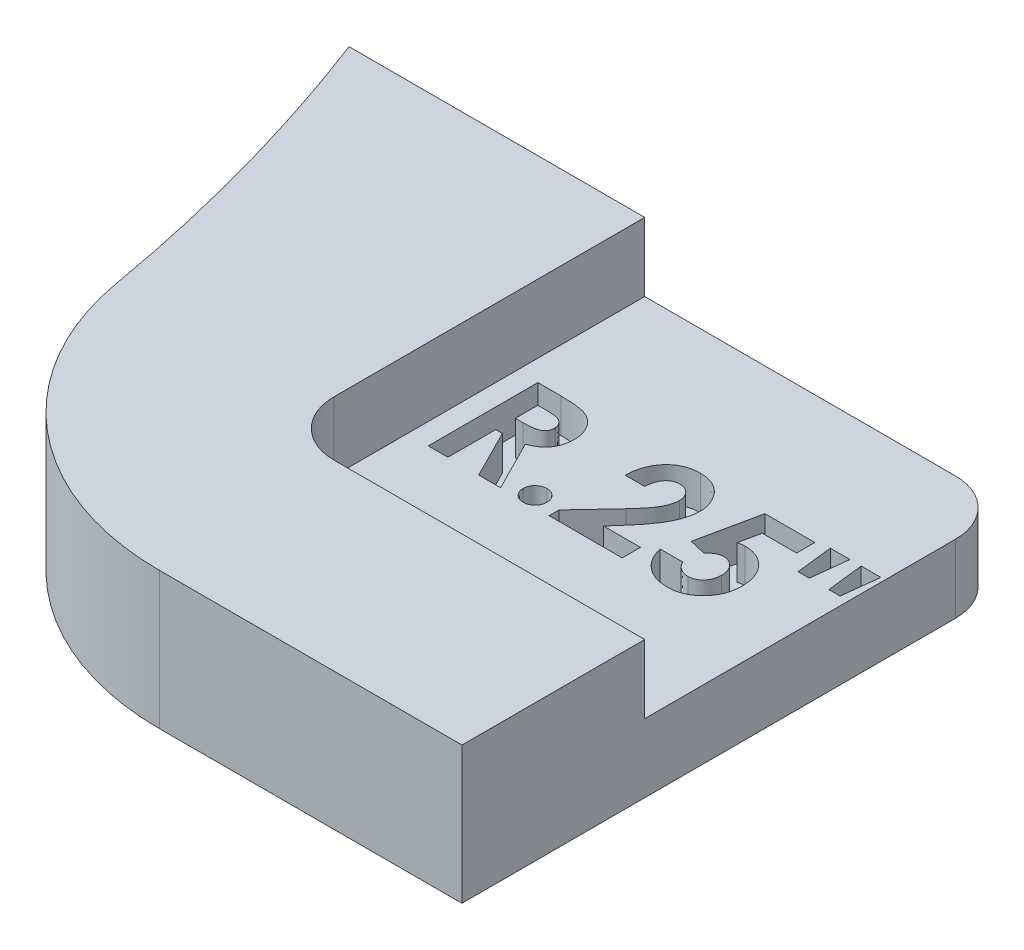
from build123d import *

# Parameters (mm, degrees)
BOSS_EXTRUDE1_DEPTH = 1.5875
FILLET1_R           = 6.35
SKETCH3_W           = 8.466666667
SKETCH3_H           = 8.466666667
CUT_EXTRUDE1_DEPTH  = 1.5875
CUT_EXTRUDE2_DEPTH  = 0.79375
FILLET2_R           = 1.27


with BuildPart() as part:
    # Sketch2 → Boss-Extrude1 (new, symmetric)
    with BuildSketch(Plane(origin=(0, 0, 0), x_dir=(1, 0, 0), z_dir=(0, 1, 0))):
        with BuildLine():
            Line((39.871809281, 1.5875), (52.571809281, 1.5875))
            Line((52.571809281, 1.5875), (52.571809281, 14.2875))
            Line((52.571809281, 14.2875), (37.257867294, 14.2875))
            ThreePointArc((37.257867294, 14.2875), (39.084130438, 8.044381855), (39.871809281, 1.5875))
        make_face()
    extrude(amount=BOSS_EXTRUDE1_DEPTH, both=True)

    # Fillet1
    fillet1_edges = [part.edges().sort_by_distance(p)[0] for p in [
        (39.871809281, 0, -1.5875),
    ]]
    fillet(fillet1_edges, radius=FILLET1_R)

    # Sketch3 → Cut-Extrude1 (cut)
    with BuildSketch(Plane(origin=(0, 1.5875, 0), x_dir=(1, 0, 0), z_dir=(0, 1, 0))):
        with Locations((48.338475948, 10.054166667)):
            Rectangle(SKETCH3_W, SKETCH3_H)
    extrude(amount=-CUT_EXTRUDE1_DEPTH, mode=Mode.SUBTRACT)

    # Sketch4 → Cut-Extrude2 (cut)
    with BuildSketch(Plane(origin=(0, 0, 0), x_dir=(1, 0, 0), z_dir=(0, 1, 0))):
        with BuildLine():
            Line((44.593604152, 11.324166667), (45.124806075, 11.324166667))
            add(Edge.make_bspline(
                [(45.124806075, 11.324166667), (45.159918361, 11.324042038), (45.227449176, 11.323802343), (45.324824924, 11.32002058), (45.414277939, 11.314757948), (45.495940666, 11.306727031), (45.569778167, 11.296079006), (45.635864445, 11.283526746), (45.694197569, 11.269220755), (45.745269497, 11.251394362), (45.791359386, 11.23128646), (45.834321571, 11.208182112), (45.875103861, 11.182338593), (45.91343367, 11.153075889), (45.949644094, 11.120920429), (45.983803445, 11.085839845), (46.01542902, 11.047536669), (46.044324993, 11.006252927), (46.070661346, 10.962823378), (46.093937159, 10.917188393), (46.112865088, 10.869316234), (46.129589943, 10.819898758), (46.141636314, 10.768229533), (46.150014389, 10.714811567), (46.156148488, 10.659456824), (46.156501169, 10.621851269), (46.156681075, 10.602668269)],
                knots=[0, 0, 0, 0, 1.749336639, 3.364467119, 4.854658419, 6.213483162, 7.451590619, 8.570285859, 9.5643256, 10.440900261, 11.26203566, 12.067320669, 12.869050712, 13.665104639, 14.467235401, 15.27997916, 16.102287765, 16.939272006, 17.78853747, 18.631303466, 19.488103222, 20.351255419, 21.228522269, 22.127379805, 23.044756219, 24, 24, 24, 24], degree=3))
            add(Edge.make_bspline(
                [(46.156681075, 10.602668269), (46.156213743, 10.582645624), (46.155297389, 10.543384867), (46.150361408, 10.485714017), (46.141339985, 10.430538582), (46.127675728, 10.378020108), (46.11197044, 10.327504941), (46.091086435, 10.27992512), (46.067516771, 10.234588662), (46.03952377, 10.192136871), (46.008802818, 10.151626807), (45.973074998, 10.114610561), (45.934654923, 10.079098649), (45.891382861, 10.047315418), (45.845166284, 10.0171118), (45.795086918, 9.989739279), (45.741471598, 9.964509772), (45.703777373, 9.950440056), (45.684501588, 9.943245192)],
                knots=[0, 0, 0, 0, 1.099860209, 2.156625411, 3.176576793, 4.16617041, 5.135385252, 6.078461593, 7.016046972, 7.938469504, 8.868247731, 9.803980173, 10.76021508, 11.73834243, 12.748633912, 13.790971185, 14.870363756, 16, 16, 16, 16], degree=3))
            Line((45.684501588, 9.943245192), (46.270655434, 8.784166667))
            Line((46.270655434, 8.784166667), (45.763876588, 8.784166667))
            Line((45.763876588, 8.784166667), (45.204181075, 9.891346154))
            Line((45.204181075, 9.891346154), (45.049501588, 9.891346154))
            Line((45.049501588, 9.891346154), (45.049501588, 8.784166667))
            Line((45.049501588, 8.784166667), (44.593604152, 8.784166667))
            Line((44.593604152, 8.784166667), (44.593604152, 11.324166667))
        make_face()
        with BuildLine():
            Line((45.049501588, 10.34724359), (45.22707771, 10.34724359))
            add(Edge.make_bspline(
                [(45.22707771, 10.34724359), (45.248787867, 10.347488104), (45.290358153, 10.347956297), (45.350141684, 10.350127967), (45.404439387, 10.355360621), (45.453484436, 10.361971884), (45.497523621, 10.369605541), (45.536164127, 10.380545035), (45.570001346, 10.39226698), (45.598634306, 10.406834317), (45.623097649, 10.423400538), (45.64422018, 10.442220178), (45.661691542, 10.464001514), (45.676071363, 10.488152625), (45.687257301, 10.51488712), (45.695422179, 10.543911516), (45.699985138, 10.575556438), (45.700510122, 10.597395742), (45.70078364, 10.608774038)],
                knots=[0, 0, 0, 0, 1.688639943, 3.233382647, 4.650958383, 5.928841754, 7.082724185, 8.122798841, 9.049171256, 9.863274652, 10.613301712, 11.341792392, 12.054588806, 12.776240173, 13.521029143, 14.301969904, 15.115324896, 16, 16, 16, 16], degree=3))
            add(Edge.make_bspline(
                [(45.70078364, 10.608774038), (45.70026653, 10.622235393), (45.699250765, 10.648677731), (45.68917122, 10.686745424), (45.673126761, 10.72197968), (45.651134202, 10.754221299), (45.623437433, 10.782486528), (45.591653205, 10.807402553), (45.555095539, 10.827104281), (45.521245891, 10.840099331), (45.490450623, 10.847874404), (45.462658866, 10.853668319), (45.430475843, 10.857774633), (45.393877259, 10.86213011), (45.352956405, 10.864954416), (45.307490237, 10.867015597), (45.257609334, 10.867858927), (45.222837607, 10.868128525), (45.20468989, 10.868269231)],
                knots=[0, 0, 0, 0, 1.020303359, 2.004196876, 2.966617323, 3.9489082, 4.950758222, 5.960522915, 7.003732012, 8.091992268, 8.70421221, 9.413913587, 10.24622431, 11.166358409, 12.212345909, 13.359657661, 14.621978493, 16, 16, 16, 16], degree=3))
            Line((45.20468989, 10.868269231), (45.049501588, 10.868269231))
            Line((45.049501588, 10.868269231), (45.049501588, 10.34724359))
        make_face(mode=Mode.SUBTRACT)
        with BuildLine():
            add(Edge.make_bspline(
                [(46.824245178, 9.305192308), (46.842649217, 9.304183258), (46.878883591, 9.302196615), (46.931237321, 9.287370501), (46.978486864, 9.260733275), (47.020734269, 9.22598963), (47.05645761, 9.184188387), (47.082277634, 9.13651918), (47.09835641, 9.084367176), (47.100131518, 9.048018804), (47.10104005, 9.029415064)],
                knots=[0, 0, 0, 0, 1.016957001, 2.002212695, 2.9757545, 3.99499976, 5.013036768, 5.994806404, 6.97370641, 8, 8, 8, 8], degree=3))
            add(Edge.make_bspline(
                [(47.10104005, 9.029415064), (47.10013747, 9.010808336), (47.09837399, 8.974454126), (47.08216637, 8.9222005), (47.056496194, 8.874139496), (47.020731403, 8.831890325), (46.978661825, 8.796491904), (46.931128686, 8.770100312), (46.878983324, 8.754433151), (46.842666771, 8.752555171), (46.824245178, 8.751602564)],
                knots=[0, 0, 0, 0, 1.023218912, 1.999186227, 2.986238111, 4.008388923, 5.030539734, 6.0011649, 6.986089706, 8, 8, 8, 8], degree=3))
            add(Edge.make_bspline(
                [(46.824245178, 8.751602564), (46.80581922, 8.752547424), (46.769494062, 8.754410133), (46.717267643, 8.770232371), (46.669383578, 8.796315704), (46.62730343, 8.831933263), (46.591378858, 8.873989888), (46.566438508, 8.922352141), (46.550079919, 8.974434426), (46.548340547, 9.010801666), (46.547450306, 9.029415064)],
                knots=[0, 0, 0, 0, 1.013427518, 1.99788335, 2.976245624, 3.997909735, 5.019573847, 6.001765691, 6.977268297, 8, 8, 8, 8], degree=3))
            add(Edge.make_bspline(
                [(46.547450306, 9.029415064), (46.548346421, 9.04802559), (46.550097267, 9.08438722), (46.566327562, 9.136365793), (46.591418829, 9.184338808), (46.627300434, 9.225946603), (46.66955944, 9.2609081), (46.717158399, 9.287240252), (46.769593745, 9.302219802), (46.805836753, 9.304191069), (46.824245178, 9.305192308)],
                knots=[0, 0, 0, 0, 1.025808215, 2.00424526, 2.981110158, 3.998665696, 5.017428914, 5.998734231, 6.983523959, 8, 8, 8, 8], degree=3))
        make_face()
        with BuildLine():
            Line((47.915142614, 10.4775), (47.459245178, 10.4775))
            add(Edge.make_bspline(
                [(47.459245178, 10.4775), (47.461214129, 10.511986229), (47.465061341, 10.57937025), (47.480364579, 10.677247699), (47.500870393, 10.769731124), (47.528238123, 10.85649701), (47.562627468, 10.937513829), (47.603153499, 11.01305777), (47.650851565, 11.082731093), (47.704706495, 11.146197795), (47.76380398, 11.20313436), (47.826917098, 11.253617894), (47.895011249, 11.295275637), (47.966842298, 11.329556102), (48.042398012, 11.3569446), (48.122393269, 11.375256028), (48.206135425, 11.387656706), (48.263463712, 11.388741816), (48.292682678, 11.389294872)],
                knots=[0, 0, 0, 0, 1.199038563, 2.342849363, 3.436047546, 4.486744587, 5.497670872, 6.488682221, 7.459191391, 8.424610317, 9.374430501, 10.305433194, 11.225809216, 12.140057399, 13.06607119, 14.010487599, 14.985989317, 16, 16, 16, 16], degree=3))
            add(Edge.make_bspline(
                [(48.292682678, 11.389294872), (48.328548545, 11.388175762), (48.398567121, 11.385990998), (48.500309666, 11.367354235), (48.595326079, 11.336181368), (48.683547292, 11.292624652), (48.764222262, 11.23729041), (48.837337612, 11.171313383), (48.900682215, 11.093309337), (48.954657696, 11.006523895), (48.99950487, 10.914630326), (49.030931901, 10.819608564), (49.051588551, 10.723980103), (49.05379171, 10.659588737), (49.054886204, 10.62760016)],
                knots=[0, 0, 0, 0, 1.075374347, 2.099382735, 3.09057751, 4.06680945, 5.040638231, 6.016817125, 7.011024321, 8.044445721, 9.0776792, 10.070479129, 11.0414456, 12, 12, 12, 12], degree=3))
            add(Edge.make_bspline(
                [(49.054886204, 10.62760016), (49.054460066, 10.608251208), (49.053602355, 10.569306547), (49.04763858, 10.510373716), (49.038691738, 10.450343738), (49.025202081, 10.389268082), (49.008379374, 10.327129628), (48.987970997, 10.263742418), (48.963503561, 10.199465833), (48.935385375, 10.133576451), (48.901840308, 10.065860356), (48.862781741, 9.995302456), (48.81717297, 9.921965343), (48.765564892, 9.84543493), (48.707706858, 9.765831919), (48.643316426, 9.683396098), (48.573135221, 9.59783699), (48.523325646, 9.540645528), (48.497734761, 9.511262019)],
                knots=[0, 0, 0, 0, 0.728284026, 1.46585585, 2.227944881, 3.01186502, 3.81876927, 4.650621989, 5.517437689, 6.406905708, 7.346299482, 8.360816762, 9.441613733, 10.596154504, 11.834900912, 13.145207542, 14.533280747, 16, 16, 16, 16], degree=3))
            Line((48.497734761, 9.511262019), (48.232642614, 9.2075))
            Line((48.232642614, 9.2075), (49.087450306, 9.2075))
            Line((49.087450306, 9.2075), (49.087450306, 8.784166667))
            Line((49.087450306, 8.784166667), (47.394116973, 8.784166667))
            Line((47.394116973, 8.784166667), (47.394116973, 9.015168269))
            Line((47.394116973, 9.015168269), (48.146144217, 9.815532853))
            add(Edge.make_bspline(
                [(48.146144217, 9.815532853), (48.167917338, 9.838879736), (48.210085417, 9.884095726), (48.270086247, 9.950500217), (48.324381699, 10.013516494), (48.371845911, 10.073815553), (48.414969745, 10.129441538), (48.451830311, 10.182071086), (48.482764856, 10.231228406), (48.516348691, 10.290503549), (48.548242296, 10.361199705), (48.577506608, 10.442644576), (48.595345231, 10.520487115), (48.597807525, 10.571210987), (48.598988768, 10.595544872)],
                knots=[0, 0, 0, 0, 1.246127091, 2.413378631, 3.493388633, 4.492180848, 5.408488754, 6.240484944, 6.999099869, 7.674939598, 8.898438119, 10.020720584, 11.050475521, 12, 12, 12, 12], degree=3))
            add(Edge.make_bspline(
                [(48.598988768, 10.595544872), (48.598105581, 10.619086028), (48.596394266, 10.664700793), (48.5775883, 10.729587554), (48.548453444, 10.788335891), (48.507398318, 10.83919034), (48.457667702, 10.880980812), (48.400199304, 10.912063392), (48.33546166, 10.929997897), (48.290079338, 10.932242657), (48.266733159, 10.933397436)],
                knots=[0, 0, 0, 0, 1.062038974, 2.057870785, 3.028805853, 4.01125022, 4.991535629, 5.949134679, 6.94496649, 8, 8, 8, 8], degree=3))
            add(Edge.make_bspline(
                [(48.266733159, 10.933397436), (48.254672225, 10.932970847), (48.23092834, 10.932131037), (48.196026685, 10.926540653), (48.162815252, 10.916688185), (48.130924381, 10.903487264), (48.100694419, 10.885989349), (48.072201614, 10.864420381), (48.045145761, 10.839328476), (48.019650947, 10.810792094), (47.996447338, 10.778945483), (47.975837978, 10.744079497), (47.958797468, 10.706215778), (47.943794383, 10.665854185), (47.932223287, 10.622561203), (47.923798093, 10.576595933), (47.917392981, 10.528033157), (47.915906382, 10.494650815), (47.915142614, 10.4775)],
                knots=[0, 0, 0, 0, 0.903469896, 1.778625579, 2.63899355, 3.493148037, 4.358286772, 5.247621495, 6.164656832, 7.118446693, 8.109501108, 9.111810964, 10.146451449, 11.215617525, 12.33435995, 13.498009769, 14.714554818, 16, 16, 16, 16], degree=3))
        make_face()
        with BuildLine():
            Line((49.852197902, 11.324166667), (51.008732358, 11.324166667))
            Line((51.008732358, 11.324166667), (51.008732358, 10.900833333))
            Line((51.008732358, 10.900833333), (50.213455915, 10.900833333))
            Line((50.213455915, 10.900833333), (50.114237165, 10.420512821))
            add(Edge.make_bspline(
                [(50.114237165, 10.420512821), (50.12775714, 10.424278304), (50.154421309, 10.431704612), (50.194590912, 10.439152259), (50.233520855, 10.443979587), (50.259066446, 10.444623488), (50.271460723, 10.444935897)],
                knots=[0, 0, 0, 0, 1.05461699, 2.079921384, 3.068411212, 4, 4, 4, 4], degree=3))
            add(Edge.make_bspline(
                [(50.271460723, 10.444935897), (50.298469151, 10.444317015), (50.351708712, 10.443097061), (50.429591435, 10.431515721), (50.504168742, 10.413275462), (50.57521242, 10.387261089), (50.642653068, 10.353402711), (50.706572438, 10.312443564), (50.76704898, 10.26431171), (50.823008375, 10.208977014), (50.874426205, 10.148218265), (50.919131076, 10.082501249), (50.957311825, 10.012763026), (50.987679473, 9.938570106), (51.01164821, 9.86038847), (51.028968554, 9.778168017), (51.039210939, 9.691811302), (51.040592062, 9.63289629), (51.04129646, 9.602848558)],
                knots=[0, 0, 0, 0, 1.01440847, 1.999622559, 2.951875003, 3.895578053, 4.836219714, 5.782137149, 6.743708247, 7.735272588, 8.734977101, 9.730283169, 10.717124674, 11.717316708, 12.737475749, 13.78628267, 14.87096371, 16, 16, 16, 16], degree=3))
            add(Edge.make_bspline(
                [(51.04129646, 9.602848558), (51.040435675, 9.572459714), (51.038737093, 9.512493641), (51.027655406, 9.424322304), (51.008096028, 9.339874067), (50.981229266, 9.258922865), (50.945834027, 9.182063671), (50.903266408, 9.10850028), (50.852806705, 9.03877873), (50.7949501, 8.973613752), (50.732052382, 8.91405171), (50.66508116, 8.861654868), (50.594506926, 8.81756335), (50.520327978, 8.781929949), (50.442969905, 8.753737437), (50.362409226, 8.733214633), (50.278254428, 8.721445946), (50.221124255, 8.719849775), (50.192085723, 8.719038462)],
                knots=[0, 0, 0, 0, 1.06808661, 2.107647099, 3.116961351, 4.110378221, 5.100014249, 6.085620622, 7.093190682, 8.119403071, 9.144090782, 10.133780668, 11.103064255, 12.062861538, 13.020824475, 13.992378307, 14.979551724, 16, 16, 16, 16], degree=3))
            add(Edge.make_bspline(
                [(50.192085723, 8.719038462), (50.166117428, 8.719702166), (50.114902516, 8.721011131), (50.039465199, 8.729056717), (49.966735248, 8.743281388), (49.897098781, 8.763868171), (49.829823103, 8.789205801), (49.765685943, 8.820895296), (49.704334855, 8.858333244), (49.645944053, 8.900836404), (49.591462304, 8.948714564), (49.541737137, 9.00112546), (49.496467509, 9.057408477), (49.456622119, 9.118257977), (49.42232587, 9.183584058), (49.391911257, 9.252616838), (49.367016592, 9.326077238), (49.354383266, 9.377004069), (49.347963127, 9.402884615)],
                knots=[0, 0, 0, 0, 1.054957082, 2.080596141, 3.077793124, 4.061112343, 5.027190972, 5.994718051, 6.962465889, 7.943658696, 8.924948258, 9.904494768, 10.875059, 11.855380583, 12.854004648, 13.869083016, 14.917087635, 16, 16, 16, 16], degree=3))
            Line((49.347963127, 9.402884615), (49.868988768, 9.402884615))
            add(Edge.make_bspline(
                [(49.868988768, 9.402884615), (49.878513129, 9.384950451), (49.897022638, 9.350097449), (49.932231817, 9.303824852), (49.971646257, 9.264365569), (50.014910419, 9.231334075), (50.062304628, 9.206587441), (50.111897659, 9.187820739), (50.164312528, 9.176976157), (50.200009369, 9.175620477), (50.218035242, 9.174935897)],
                knots=[0, 0, 0, 0, 1.104910296, 2.147267069, 3.153527244, 4.136738762, 5.099945312, 6.05603338, 7.018353, 8, 8, 8, 8], degree=3))
            add(Edge.make_bspline(
                [(50.218035242, 9.174935897), (50.230599034, 9.175408605), (50.255318506, 9.176338666), (50.29173874, 9.181258923), (50.326503453, 9.190577776), (50.359871113, 9.203482222), (50.391931354, 9.219575524), (50.42222458, 9.239892269), (50.451277841, 9.263277596), (50.478648826, 9.290112337), (50.50343905, 9.320026832), (50.525177365, 9.352171996), (50.544614416, 9.385833557), (50.559011736, 9.422344933), (50.570801925, 9.460615882), (50.579484696, 9.500935094), (50.584673632, 9.543349657), (50.585153988, 9.572304891), (50.585399024, 9.587075321)],
                knots=[0, 0, 0, 0, 0.978869489, 1.925942215, 2.855067702, 3.774946051, 4.70828698, 5.642468714, 6.60995405, 7.609372294, 8.622401667, 9.629904756, 10.629323, 11.642352373, 12.678539694, 13.745912462, 14.850161547, 16, 16, 16, 16], degree=3))
            add(Edge.make_bspline(
                [(50.585399024, 9.587075321), (50.585114632, 9.601502895), (50.584561055, 9.629586518), (50.579981755, 9.670823337), (50.571789476, 9.709949616), (50.560627425, 9.747265031), (50.546338668, 9.782542987), (50.528876851, 9.815993475), (50.508167376, 9.847447414), (50.484099059, 9.876264433), (50.458432853, 9.902696223), (50.4308591, 9.925813255), (50.401626226, 9.944998787), (50.371642606, 9.961748315), (50.339711401, 9.973938256), (50.306550617, 9.982333019), (50.272195126, 9.988492758), (50.248761991, 9.988854665), (50.236861364, 9.989038462)],
                knots=[0, 0, 0, 0, 1.166249705, 2.270133367, 3.348514167, 4.393962215, 5.415026464, 6.420877785, 7.440098956, 8.453121383, 9.451844239, 10.415694839, 11.355045125, 12.27538808, 13.187007209, 14.108269027, 15.039275622, 16, 16, 16, 16], degree=3))
            add(Edge.make_bspline(
                [(50.236861364, 9.989038462), (50.223934517, 9.98854796), (50.198026344, 9.987564888), (50.159533283, 9.9795659), (50.121504341, 9.966620537), (50.083728038, 9.948760356), (50.04657937, 9.925387015), (50.009077964, 9.897972766), (49.972479074, 9.864525703), (49.949208482, 9.839614255), (49.937169858, 9.826726763)],
                knots=[0, 0, 0, 0, 0.88288272, 1.769486374, 2.674910571, 3.623812639, 4.617874466, 5.670434592, 6.794841017, 8, 8, 8, 8], degree=3))
            Line((49.937169858, 9.826726763), (49.553524024, 9.914751603))
            Line((49.553524024, 9.914751603), (49.852197902, 11.324166667))
        make_face()
        Polygon((52.376424665, 10.542628205), (52.115911845, 10.542628205), (52.018219537, 11.389294872), (52.474116973, 11.389294872), align=None)
        Polygon((51.660014409, 10.542628205), (51.399501588, 10.542628205), (51.301809281, 11.389294872), (51.757706717, 11.389294872), align=None)
    extrude(amount=-CUT_EXTRUDE2_DEPTH, mode=Mode.SUBTRACT)

    # Fillet2
    fillet2_edges = [part.edges().sort_by_distance(p)[0] for p in [
        (52.571809281, -0.79375, -14.2875),
        (44.105142614, 0.79375, -5.820833333),
    ]]
    fillet(fillet2_edges, radius=FILLET2_R)


solid = part.part
